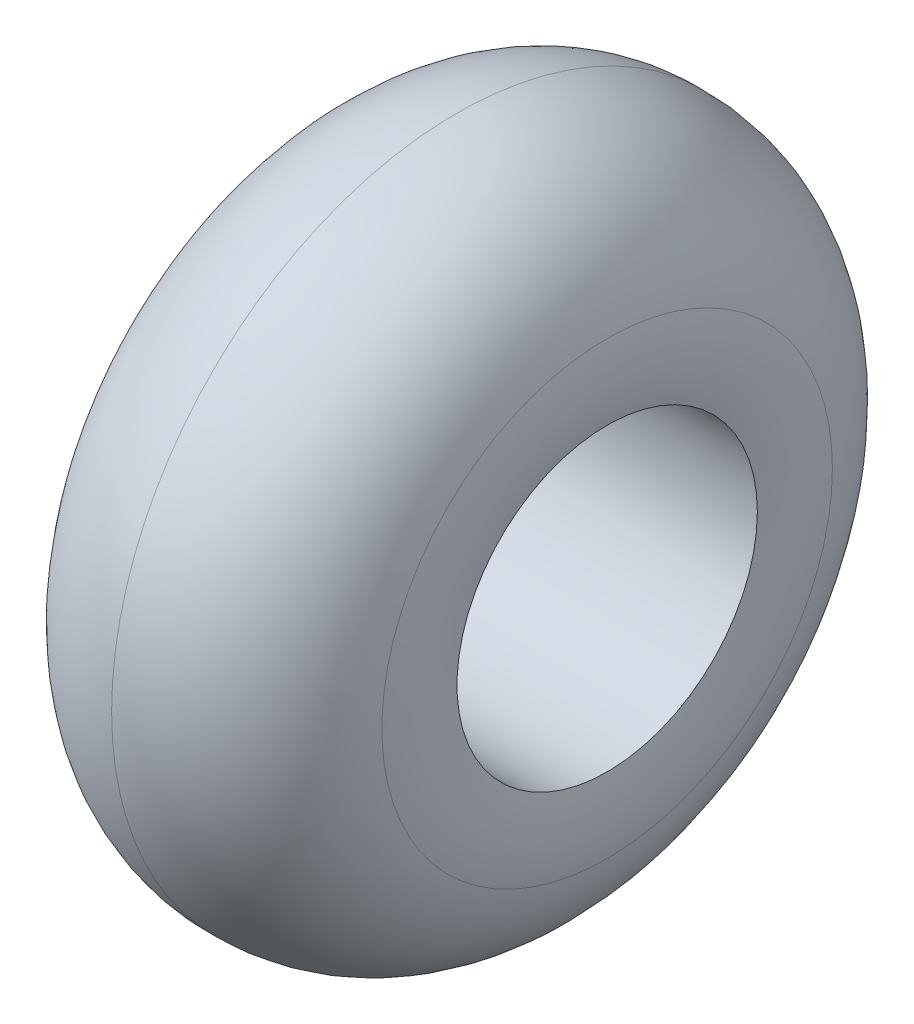
from build123d import *


with BuildPart() as part:
    # Sketch2 → Revolve1 (revolve)
    with BuildSketch(Plane.XY):
        with BuildLine():
            Line((-63.5, 63.5), (63.5, 63.5))
            ThreePointArc((63.5, 63.5), (65.171989326, 79.375), (63.5, 95.25))
            ThreePointArc((63.5, 95.25), (40.948462472, 132.14807809), (0, 146.05))
            ThreePointArc((0, 146.05), (-40.948462472, 132.14807809), (-63.5, 95.25))
            ThreePointArc((-63.5, 95.25), (-65.171989326, 79.375), (-63.5, 63.5))
        make_face()
    revolve(axis=Axis((0, 0, 0), (-1, 0, 0)))


solid = part.part
